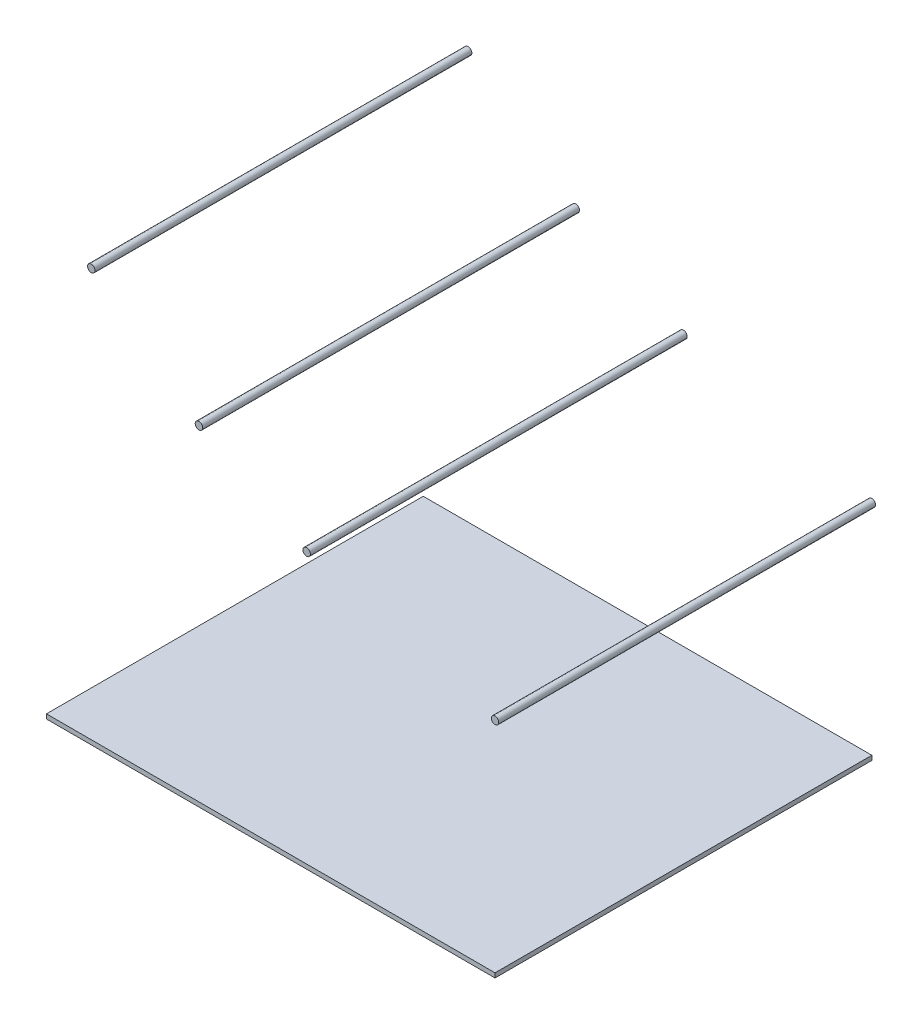
from build123d import *

# Parameters (mm, degrees)
SKETCH1_R             = 21.082
BOSS_EXTRUDE1_DEPTH   = 1066.8
BOSS_EXTRUDE1_2_DEPTH = 1066.8
BOSS_EXTRUDE1_3_DEPTH = 1066.8
BOSS_EXTRUDE1_4_DEPTH = 1066.8
SKETCH1_W             = 2540
SKETCH1_H             = 25.4
BOSS_EXTRUDE1_5_DEPTH = 1066.8


with BuildPart() as part:
    # Sketch1 → Boss-Extrude1 (new body, symmetric)
    with BuildSketch(Plane.XY):
        with Locations((0, 1238.25)):
            Circle(SKETCH1_R)
    extrude(amount=BOSS_EXTRUDE1_DEPTH, both=True)


with BuildPart() as body_2:
    # Sketch1 → Boss-Extrude1 2 (new body, symmetric)
    with BuildSketch(Plane.XY):
        with Locations((-1066.8, 1530.35)):
            Circle(SKETCH1_R)
    extrude(amount=BOSS_EXTRUDE1_2_DEPTH, both=True)


with BuildPart() as body_3:
    # Sketch1 → Boss-Extrude1 3 (new body, symmetric)
    with BuildSketch(Plane.XY):
        with Locations((-1676.4, 1844.675)):
            Circle(SKETCH1_R)
    extrude(amount=BOSS_EXTRUDE1_3_DEPTH, both=True)


with BuildPart() as body_4:
    # Sketch1 → Boss-Extrude1 4 (new body, symmetric)
    with BuildSketch(Plane.XY):
        with Locations((-2286, 2311.4)):
            Circle(SKETCH1_R)
    extrude(amount=BOSS_EXTRUDE1_4_DEPTH, both=True)


with BuildPart() as body_5:
    # Sketch1 → Boss-Extrude1 5 (new body, symmetric)
    with BuildSketch(Plane.XY):
        with Locations((-1270, -12.7)):
            Rectangle(SKETCH1_W, SKETCH1_H)
    extrude(amount=BOSS_EXTRUDE1_5_DEPTH, both=True)


solid = Compound([part.part, body_2.part, body_3.part, body_4.part, body_5.part])
